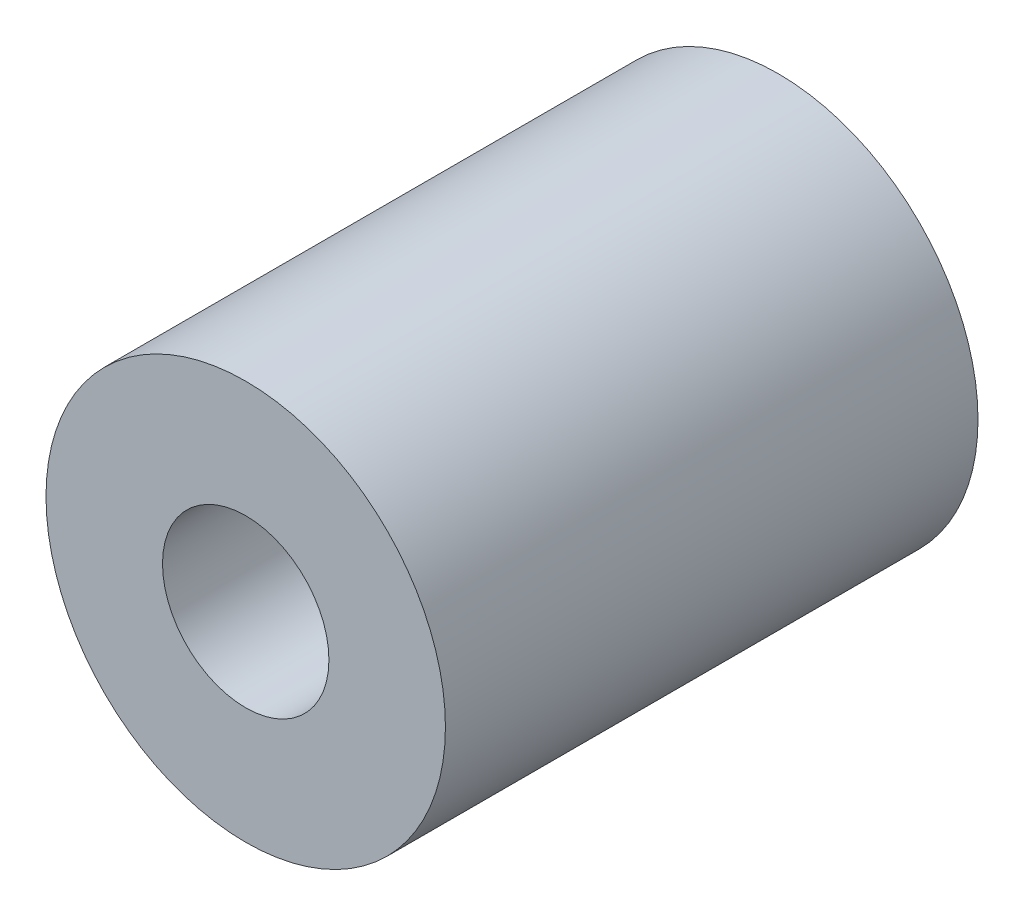
from build123d import *

# Parameters (mm, degrees)
SKETCH1_R           = 7.62
SKETCH1_R_2         = 3.175
BOSS_EXTRUDE1_DEPTH = 20.32


with BuildPart() as part:
    # Sketch1 → Boss-Extrude1 (new body)
    with BuildSketch(Plane.XY):
        Circle(SKETCH1_R)
        Circle(SKETCH1_R_2, mode=Mode.SUBTRACT)
    extrude(amount=BOSS_EXTRUDE1_DEPTH)


solid = part.part
